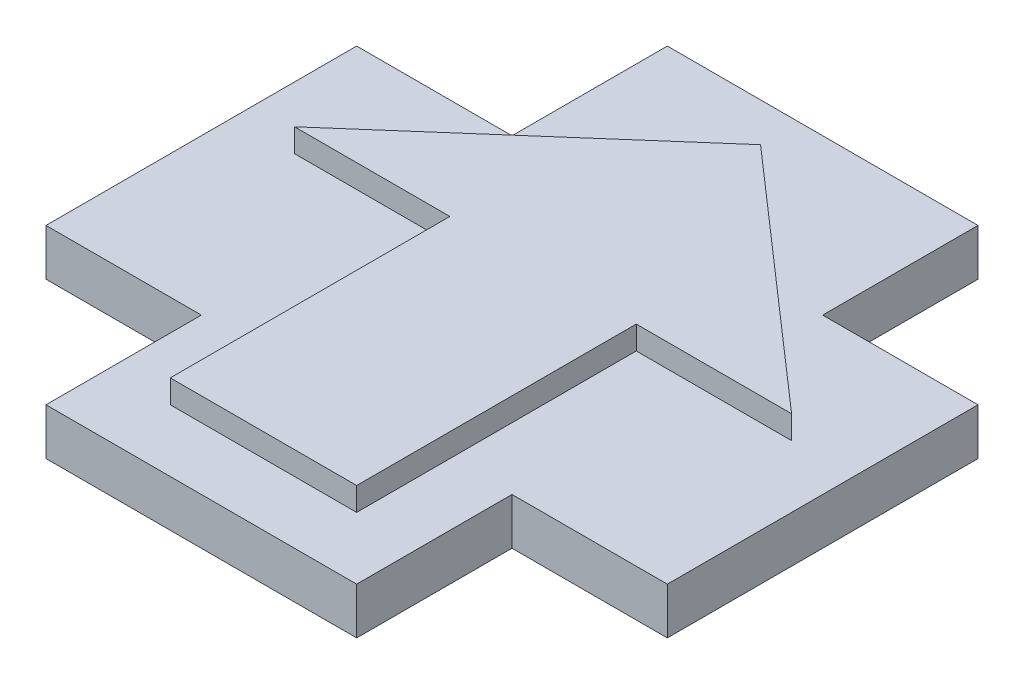
from build123d import *

# Parameters (mm, degrees)
SKETCH1_W                = 6
SKETCH1_H                = 3
BOSS_EXTRUDE2_DEPTH      = 3
SKETCH4_W                = 2
SKETCH4_H                = 6
BOSS_EXTRUDE3_DEPTH      = 0.75
BOSS_EXTRUDE3_DEPTH_BACK = 0.75


with BuildPart() as part:
    # Sketch1 → Boss-Extrude2 (new body)
    with BuildSketch(Plane(origin=(0, 0, 0), x_dir=(1, 0, 0), z_dir=(0, 1, 0))):
        Polygon((-5, 3.625), (-5, 1), (-3, 1), (-3, -5), (3, -5), (3, 1), (5, 1), (5, 3.625), (3.428571429, 5), (-3.428571429, 5), align=None)
        with Locations((0, -6.5)):
            Rectangle(SKETCH1_W, SKETCH1_H)
        Polygon((-5, 3.625), (-8, 1), (-5, 1), align=None)
        Polygon((0, 8), (-3.428571429, 5), (3.428571429, 5), align=None)
        Polygon((8, 1), (5, 3.625), (5, 1), align=None)
    extrude(amount=BOSS_EXTRUDE2_DEPTH)

    # Sketch4 → Boss-Extrude3 (add, two sides)
    with BuildSketch(Plane(origin=(0, 1.5, 0), x_dir=(1, 0, 0), z_dir=(0, 1, 0))) as boss_extrude3_sk:
        Polygon((10, -5), (10, 5), (5, 5), (5, 3.625), (8, 1), (5, 1), (5, -5), align=None)
        with Locations((4, -2)):
            Rectangle(SKETCH4_W, SKETCH4_H)
        Polygon((3.428571429, 5), (5, 5), (5, 10), (-5, 10), (-5, 5), (-3.428571429, 5), (0, 8), align=None)
        Polygon((-5, 3.625), (-5, 5), (-10, 5), (-10, -5), (-5, -5), (-5, 1), (-8, 1), align=None)
        Polygon((-5, 3.625), (-3.428571429, 5), (-5, 5), align=None)
        Polygon((5, 3.625), (5, 5), (3.428571429, 5), align=None)
        with Locations((-4, -2)):
            Rectangle(SKETCH4_W, SKETCH4_H)
        Polygon((5, -10), (5, -5), (3, -5), (3, -8), (-3, -8), (-3, -5), (-5, -5), (-5, -10), align=None)
    extrude(amount=BOSS_EXTRUDE3_DEPTH)
    extrude(boss_extrude3_sk.sketch, amount=-BOSS_EXTRUDE3_DEPTH_BACK)


solid = part.part
